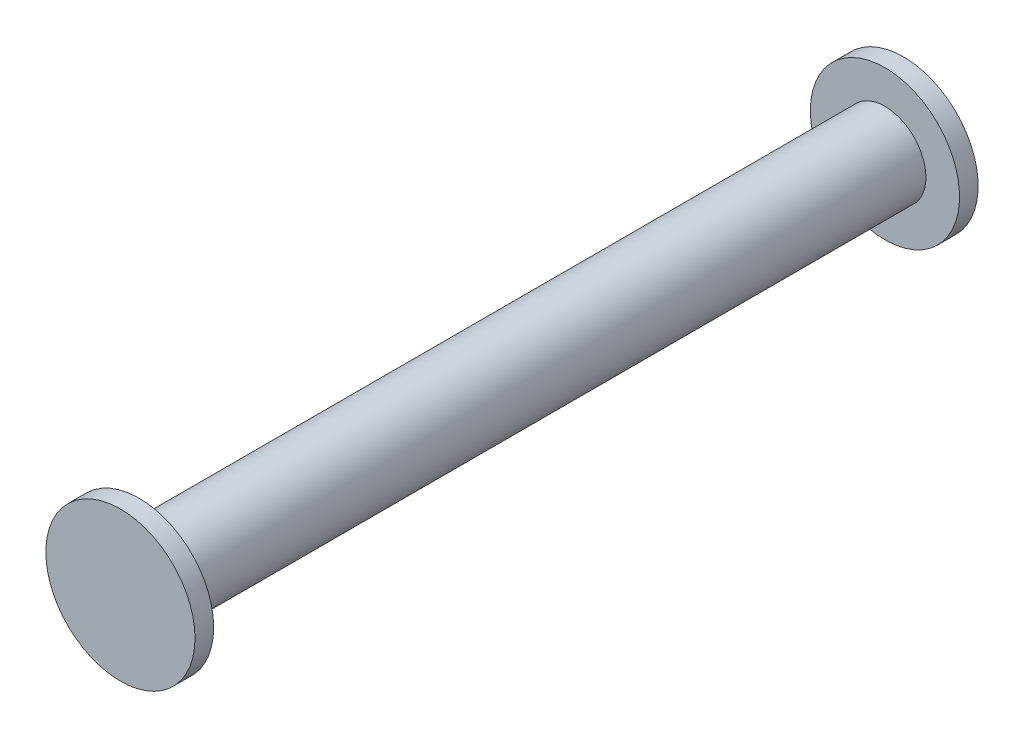
from build123d import *

# Parameters (mm, degrees)
SKETCH1_R           = 2.2
BOSS_EXTRUDE1_DEPTH = 40
SKETCH2_R           = 4
BOSS_EXTRUDE2_DEPTH = 1
SKETCH3_R           = 4
BOSS_EXTRUDE3_DEPTH = 1


with BuildPart() as part:
    # Sketch1 → Boss-Extrude1 (new body)
    with BuildSketch(Plane.XY):
        with Locations((-44.111688034, 4.888301887)):
            Circle(SKETCH1_R)
    extrude(amount=-BOSS_EXTRUDE1_DEPTH)

    # Sketch2 → Boss-Extrude2 (add)
    with BuildSketch(Plane.XY):
        with Locations((-44.111688034, 4.888301887)):
            Circle(SKETCH2_R)
    extrude(amount=BOSS_EXTRUDE2_DEPTH)

    # Sketch3 → Boss-Extrude3 (add)
    with BuildSketch(Plane(origin=(0, 0, -40), x_dir=(-1, 0, 0), z_dir=(0, 0, -1))):
        with Locations((44.111688034, 4.888301887)):
            Circle(SKETCH3_R)
    extrude(amount=BOSS_EXTRUDE3_DEPTH)


solid = part.part
